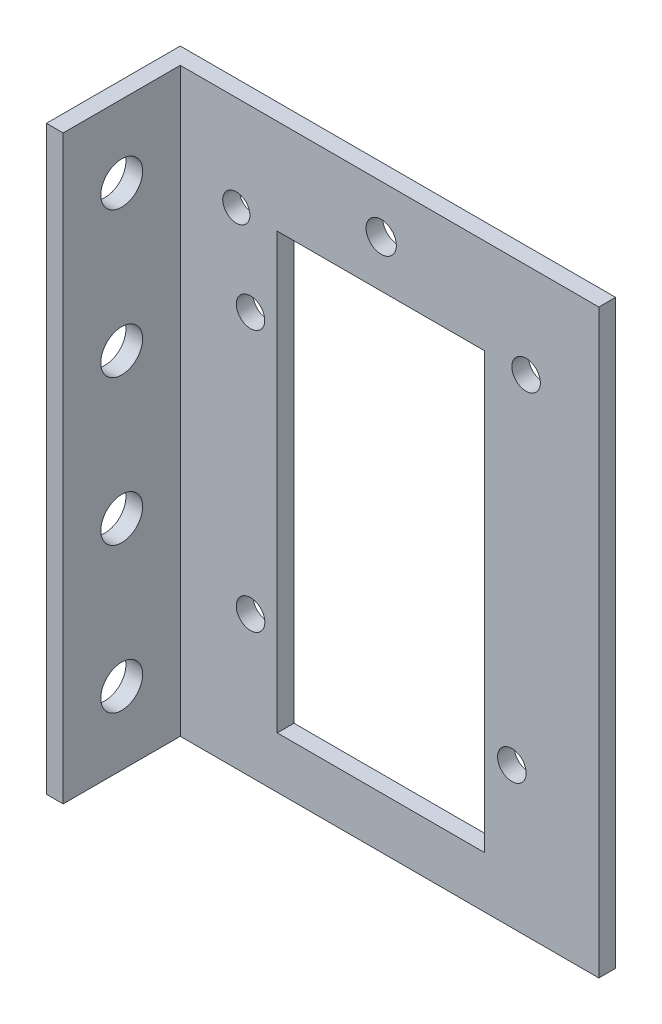
from build123d import *

# Parameters (mm, degrees)
SKETCH2_R           = 2.168725958
SKETCH2_R_2         = 2.299626563
SKETCH2_R_3         = 2.061813599
SKETCH2_R_4         = 2.159
BOSS_EXTRUDE1_DEPTH = 2.54
SKETCH3_W           = 2.54
SKETCH3_H           = 88.215633797
BOSS_EXTRUDE2_DEPTH = 17.78
SKETCH5_R           = 3.175
CUT_EXTRUDE2_DEPTH  = 17.78


with BuildPart() as part:
    # Sketch2 → Boss-Extrude1 (new body)
    with BuildSketch(Plane.XY):
        Polygon((33.041228817, 37.6809), (33.041228817, 9.671924958), (33.041228817, -38.409527683), (33.041228817, -46.223073917), (-33.041228817, -46.223073917), (-33.041228817, -38.409527683), (-33.041228817, 9.671924958), (-33.041228817, 37.6809), (-33.041228817, 41.99255988), (33.041228817, 41.99255988), align=None)
        with Locations((19.8374, -24.8158)):
            Circle(SKETCH2_R, mode=Mode.SUBTRACT)
        with Locations((21.996003552, 27.558503658)):
            Circle(SKETCH2_R, mode=Mode.SUBTRACT)
        with Locations((-0.000312071, 34.695463786)):
            Circle(SKETCH2_R_2, mode=Mode.SUBTRACT)
        with Locations((-21.9964, 27.559)):
            Circle(SKETCH2_R_3, mode=Mode.SUBTRACT)
        with Locations((-19.8374, 14.859)):
            Circle(SKETCH2_R_4, mode=Mode.SUBTRACT)
        with Locations((-19.8374, -24.8158)):
            Circle(SKETCH2_R, mode=Mode.SUBTRACT)
        Polygon((15.652792396, 9.671924958), (15.652792396, 27.558503658), (-13.85744492, 27.558503658), (-15.780925581, 27.558503658), (-15.780925581, 9.671924958), (-15.780925581, -38.409527683), (15.652792396, -38.409527683), align=None, mode=Mode.SUBTRACT)
    extrude(amount=BOSS_EXTRUDE1_DEPTH)

    # Sketch3 → Boss-Extrude2 (add)
    with BuildSketch(Plane.XY.offset(2.54)):
        with Locations((-31.771228817, -2.115257018)):
            Rectangle(SKETCH3_W, SKETCH3_H)
    extrude(amount=BOSS_EXTRUDE2_DEPTH)

    # Sketch5 → Cut-Extrude2 (cut)
    with BuildSketch(Plane(origin=(-30.501228817, 0, 0), x_dir=(0, 0, -1), z_dir=(1, 0, 0))):
        with Locations((-11.43, -35.196119692)):
            Circle(SKETCH5_R)
        with Locations((-11.43, -13.142211243)):
            Circle(SKETCH5_R)
        with Locations((-11.43, 8.911697206)):
            Circle(SKETCH5_R)
        with Locations((-11.43, 30.965605655)):
            Circle(SKETCH5_R)
    extrude(amount=-CUT_EXTRUDE2_DEPTH, mode=Mode.SUBTRACT)


solid = part.part
